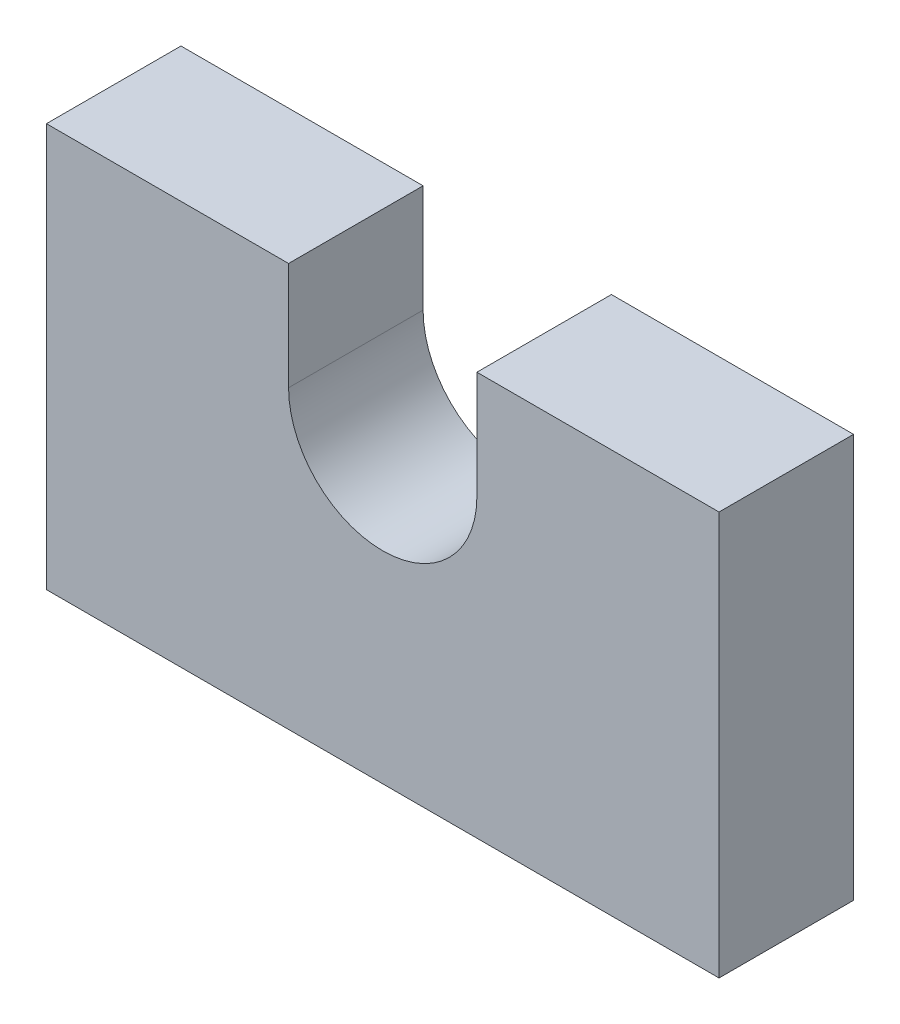
from build123d import *

# Parameters (mm, degrees)
BOSS_EXTRUDE1_DEPTH = 50


with BuildPart() as part:
    # Sketch3 → Boss-Extrude1 (new body)
    with BuildSketch(Plane.XY):
        with BuildLine():
            Line((-125, 0), (125, 0))
            Line((125, 0), (125, 150))
            Line((125, 150), (35, 150))
            Line((35, 150), (35, 110))
            ThreePointArc((35, 110), (0, 75), (-35, 110))
            Line((-35, 110), (-35, 150))
            Line((-35, 150), (-125, 150))
            Line((-125, 150), (-125, 0))
        make_face()
    extrude(amount=BOSS_EXTRUDE1_DEPTH)


solid = part.part
